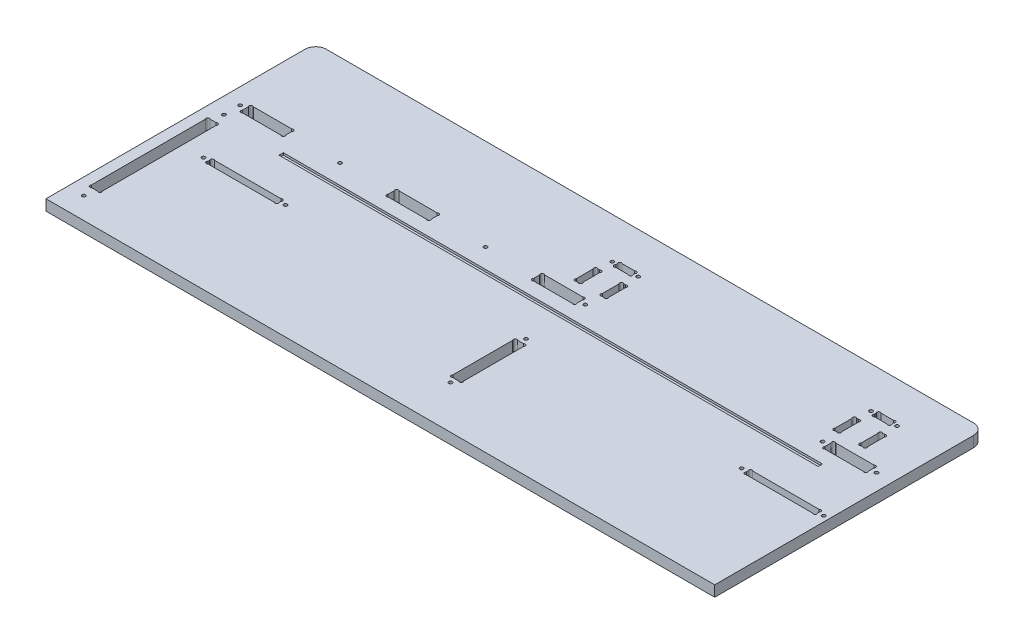
from build123d import *

# Parameters (mm, degrees)
ESQUISSE1_R             = 1.6
EXTRUSION1_DEPTH        = 10
ESQUISSE2_W             = 500
ESQUISSE2_H             = 4
ENL_V_MAT_EXTRU_1_DEPTH = 2


with BuildPart() as part:
    # Esquisse1 → Extrusion1 (new body)
    with BuildSketch(Plane(origin=(0, 0, 0), x_dir=(1, 0, 0), z_dir=(0, 1, 0))):
        with BuildLine():
            Line((10, 250), (610, 250))
            ThreePointArc((610, 250), (617.071067812, 247.071067812), (620, 240))
            Line((620, 240), (620, 0))
            Line((620, 0), (0, 0))
            Line((0, 0), (0, 240))
            ThreePointArc((0, 240), (2.928932188, 247.071067812), (10, 250))
        make_face()
        with Locations(Location((313, 212, 0), (0, 0, 270))):  # turned: the seam where the file's is
            Circle(ESQUISSE1_R, mode=Mode.SUBTRACT)
        with Locations(Location((337, 212, 0), (0, 0, 90))):  # turned: the seam where the file's is
            Circle(ESQUISSE1_R, mode=Mode.SUBTRACT)
        with Locations(Location((553, 212, 0), (0, 0, 270))):  # turned: the seam where the file's is
            Circle(ESQUISSE1_R, mode=Mode.SUBTRACT)
        with Locations(Location((577, 212, 0), (0, 0, 90))):  # turned: the seam where the file's is
            Circle(ESQUISSE1_R, mode=Mode.SUBTRACT)
        with Locations(Location((555, 165, 0), (0, 0, 270))):  # turned: the seam where the file's is
            Circle(ESQUISSE1_R, mode=Mode.SUBTRACT)
        with Locations(Location((605, 165, 0), (0, 0, 90))):  # turned: the seam where the file's is
            Circle(ESQUISSE1_R, mode=Mode.SUBTRACT)
        with Locations(Location((335, 165, 0), (0, 0, 90))):  # turned: the seam where the file's is
            Circle(ESQUISSE1_R, mode=Mode.SUBTRACT)
        with Locations(Location((15, 165, 0), (0, 0, 270))):  # turned: the seam where the file's is
            Circle(ESQUISSE1_R, mode=Mode.SUBTRACT)
        with Locations(Location((242.5, 165, 0), (0, 0, 270))):  # turned: the seam where the file's is
            Circle(ESQUISSE1_R, mode=Mode.SUBTRACT)
        with Locations(Location((107.5, 165, 0), (0, 0, 90))):  # turned: the seam where the file's is
            Circle(ESQUISSE1_R, mode=Mode.SUBTRACT)
        with Locations(Location((15, 20, 0), (0, 0, 270))):  # turned: the seam where the file's is
            Circle(ESQUISSE1_R, mode=Mode.SUBTRACT)
        with Locations(Location((15, 150, 0), (0, 0, 90))):  # turned: the seam where the file's is
            Circle(ESQUISSE1_R, mode=Mode.SUBTRACT)
        with Locations(Location((335, 40, 0), (0, 0, 270))):  # turned: the seam where the file's is
            Circle(ESQUISSE1_R, mode=Mode.SUBTRACT)
        with Locations(Location((335, 110, 0), (0, 0, 90))):  # turned: the seam where the file's is
            Circle(ESQUISSE1_R, mode=Mode.SUBTRACT)
        with Locations(Location((615, 106, 0), (0, 0, 270))):  # turned: the seam where the file's is
            Circle(ESQUISSE1_R, mode=Mode.SUBTRACT)
        with Locations(Location((539, 106, 0), (0, 0, 90))):  # turned: the seam where the file's is
            Circle(ESQUISSE1_R, mode=Mode.SUBTRACT)
        with Locations(Location((116, 106, 0), (0, 0, 270))):  # turned: the seam where the file's is
            Circle(ESQUISSE1_R, mode=Mode.SUBTRACT)
        with Locations(Location((40, 106, 0), (0, 0, 90))):  # turned: the seam where the file's is
            Circle(ESQUISSE1_R, mode=Mode.SUBTRACT)
        with BuildLine():
            Line((317, 211.2627417), (317, 212.7372583))
            ThreePointArc((317, 212.7372583), (317, 215), (319.2627417, 215))
            Line((319.2627417, 215), (330.7372583, 215))
            ThreePointArc((330.7372583, 215), (333, 215), (333, 212.7372583))
            Line((333, 212.7372583), (333, 211.2627417))
            ThreePointArc((333, 211.2627417), (333, 209), (330.7372583, 209))
            Line((330.7372583, 209), (319.2627417, 209))
            ThreePointArc((319.2627417, 209), (317, 209), (317, 211.2627417))
        make_face(mode=Mode.SUBTRACT)
        with BuildLine():
            Line((312.2627417, 179.5), (313.7372583, 179.5))
            ThreePointArc((313.7372583, 179.5), (316, 179.5), (316, 181.7627417))
            Line((316, 181.7627417), (316, 197.2372583))
            ThreePointArc((316, 197.2372583), (316, 199.5), (313.7372583, 199.5))
            Line((313.7372583, 199.5), (312.2627417, 199.5))
            ThreePointArc((312.2627417, 199.5), (310, 199.5), (310, 197.2372583))
            Line((310, 197.2372583), (310, 181.7627417))
            ThreePointArc((310, 181.7627417), (310, 179.5), (312.2627417, 179.5))
        make_face(mode=Mode.SUBTRACT)
        with BuildLine():
            Line((334, 181.7627417), (334, 197.2372583))
            ThreePointArc((334, 197.2372583), (334, 199.5), (336.2627417, 199.5))
            Line((336.2627417, 199.5), (337.7372583, 199.5))
            ThreePointArc((337.7372583, 199.5), (340, 199.5), (340, 197.2372583))
            Line((340, 197.2372583), (340, 181.7627417))
            ThreePointArc((340, 181.7627417), (340, 179.5), (337.7372583, 179.5))
            Line((337.7372583, 179.5), (336.2627417, 179.5))
            ThreePointArc((336.2627417, 179.5), (334, 179.5), (334, 181.7627417))
        make_face(mode=Mode.SUBTRACT)
        with BuildLine():
            Line((552.2627417, 179.5), (553.7372583, 179.5))
            ThreePointArc((553.7372583, 179.5), (556, 179.5), (556, 181.7627417))
            Line((556, 181.7627417), (556, 197.2372583))
            ThreePointArc((556, 197.2372583), (556, 199.5), (553.7372583, 199.5))
            Line((553.7372583, 199.5), (552.2627417, 199.5))
            ThreePointArc((552.2627417, 199.5), (550, 199.5), (550, 197.2372583))
            Line((550, 197.2372583), (550, 181.7627417))
            ThreePointArc((550, 181.7627417), (550, 179.5), (552.2627417, 179.5))
        make_face(mode=Mode.SUBTRACT)
        with BuildLine():
            Line((574, 181.7627417), (574, 197.2372583))
            ThreePointArc((574, 197.2372583), (574, 199.5), (576.2627417, 199.5))
            Line((576.2627417, 199.5), (577.7372583, 199.5))
            ThreePointArc((577.7372583, 199.5), (580, 199.5), (580, 197.2372583))
            Line((580, 197.2372583), (580, 181.7627417))
            ThreePointArc((580, 181.7627417), (580, 179.5), (577.7372583, 179.5))
            Line((577.7372583, 179.5), (576.2627417, 179.5))
            ThreePointArc((576.2627417, 179.5), (574, 179.5), (574, 181.7627417))
        make_face(mode=Mode.SUBTRACT)
        with BuildLine():
            Line((559.2627417, 209), (570.7372583, 209))
            ThreePointArc((570.7372583, 209), (573, 209), (573, 211.2627417))
            Line((573, 211.2627417), (573, 212.7372583))
            ThreePointArc((573, 212.7372583), (573, 215), (570.7372583, 215))
            Line((570.7372583, 215), (559.2627417, 215))
            ThreePointArc((559.2627417, 215), (557, 215), (557, 212.7372583))
            Line((557, 212.7372583), (557, 211.2627417))
            ThreePointArc((557, 211.2627417), (557, 209), (559.2627417, 209))
        make_face(mode=Mode.SUBTRACT)
        with BuildLine():
            Line((560, 167.7372583), (560, 162.2627417))
            ThreePointArc((560, 162.2627417), (560, 160), (562.2627417, 160))
            Line((562.2627417, 160), (597.7372583, 160))
            ThreePointArc((597.7372583, 160), (600, 160), (600, 162.2627417))
            Line((600, 162.2627417), (600, 167.7372583))
            ThreePointArc((600, 167.7372583), (600, 170), (597.7372583, 170))
            Line((597.7372583, 170), (562.2627417, 170))
            ThreePointArc((562.2627417, 170), (560, 170), (560, 167.7372583))
        make_face(mode=Mode.SUBTRACT)
        with BuildLine():
            Line((292.2627417, 160), (327.7372583, 160))
            ThreePointArc((327.7372583, 160), (330, 160), (330, 162.2627417))
            Line((330, 162.2627417), (330, 167.7372583))
            ThreePointArc((330, 167.7372583), (330, 170), (327.7372583, 170))
            Line((327.7372583, 170), (292.2627417, 170))
            ThreePointArc((292.2627417, 170), (290, 170), (290, 167.7372583))
            Line((290, 167.7372583), (290, 162.2627417))
            ThreePointArc((290, 162.2627417), (290, 160), (292.2627417, 160))
        make_face(mode=Mode.SUBTRACT)
        with BuildLine():
            Line((20, 167.7372583), (20, 162.2627417))
            ThreePointArc((20, 162.2627417), (20, 160), (22.2627417, 160))
            Line((22.2627417, 160), (57.7372583, 160))
            ThreePointArc((57.7372583, 160), (60, 160), (60, 162.2627417))
            Line((60, 162.2627417), (60, 167.7372583))
            ThreePointArc((60, 167.7372583), (60, 170), (57.7372583, 170))
            Line((57.7372583, 170), (22.2627417, 170))
            ThreePointArc((22.2627417, 170), (20, 170), (20, 167.7372583))
        make_face(mode=Mode.SUBTRACT)
        with BuildLine():
            Line((155, 167.7372583), (155, 162.2627417))
            ThreePointArc((155, 162.2627417), (155, 160), (157.2627417, 160))
            Line((157.2627417, 160), (192.7372583, 160))
            ThreePointArc((192.7372583, 160), (195, 160), (195, 162.2627417))
            Line((195, 162.2627417), (195, 167.7372583))
            ThreePointArc((195, 167.7372583), (195, 170), (192.7372583, 170))
            Line((192.7372583, 170), (157.2627417, 170))
            ThreePointArc((157.2627417, 170), (155, 170), (155, 167.7372583))
        make_face(mode=Mode.SUBTRACT)
        with BuildLine():
            Line((12.2627417, 30), (17.7372583, 30))
            ThreePointArc((17.7372583, 30), (20, 30), (20, 32.2627417))
            Line((20, 32.2627417), (20, 137.7372583))
            ThreePointArc((20, 137.7372583), (20, 140), (17.7372583, 140))
            Line((17.7372583, 140), (12.2627417, 140))
            ThreePointArc((12.2627417, 140), (10, 140), (10, 137.7372583))
            Line((10, 137.7372583), (10, 32.2627417))
            ThreePointArc((10, 32.2627417), (10, 30), (12.2627417, 30))
        make_face(mode=Mode.SUBTRACT)
        with BuildLine():
            Line((337.7372583, 45), (332.2627417, 45))
            ThreePointArc((332.2627417, 45), (330, 45), (330, 47.2627417))
            Line((330, 47.2627417), (330, 102.7372583))
            ThreePointArc((330, 102.7372583), (330, 105), (332.2627417, 105))
            Line((332.2627417, 105), (337.7372583, 105))
            ThreePointArc((337.7372583, 105), (340, 105), (340, 102.7372583))
            Line((340, 102.7372583), (340, 47.2627417))
            ThreePointArc((340, 47.2627417), (340, 45), (337.7372583, 45))
        make_face(mode=Mode.SUBTRACT)
        with BuildLine():
            Line((610, 105.2627417), (610, 106.7372583))
            ThreePointArc((610, 106.7372583), (610, 109), (607.7372583, 109))
            Line((607.7372583, 109), (546.2627417, 109))
            ThreePointArc((546.2627417, 109), (544, 109), (544, 106.7372583))
            Line((544, 106.7372583), (544, 105.2627417))
            ThreePointArc((544, 105.2627417), (544, 103), (546.2627417, 103))
            Line((546.2627417, 103), (607.7372583, 103))
            ThreePointArc((607.7372583, 103), (610, 103), (610, 105.2627417))
        make_face(mode=Mode.SUBTRACT)
        with BuildLine():
            Line((108.7372583, 109), (47.2627417, 109))
            ThreePointArc((47.2627417, 109), (45, 109), (45, 106.7372583))
            Line((45, 106.7372583), (45, 105.2627417))
            ThreePointArc((45, 105.2627417), (45, 103), (47.2627417, 103))
            Line((47.2627417, 103), (108.7372583, 103))
            ThreePointArc((108.7372583, 103), (111, 103), (111, 105.2627417))
            Line((111, 105.2627417), (111, 106.7372583))
            ThreePointArc((111, 106.7372583), (111, 109), (108.7372583, 109))
        make_face(mode=Mode.SUBTRACT)
    extrude(amount=EXTRUSION1_DEPTH)

    # Esquisse2 → Enlèv. mat.-Extru.1 (cut)
    with BuildSketch(Plane(origin=(0, 10, 0), x_dir=(-1, 0, 0), z_dir=(0, 1, 0))):
        with Locations((-323, -145)):
            Rectangle(ESQUISSE2_W, ESQUISSE2_H)
    extrude(amount=-ENL_V_MAT_EXTRU_1_DEPTH, mode=Mode.SUBTRACT)


solid = part.part
